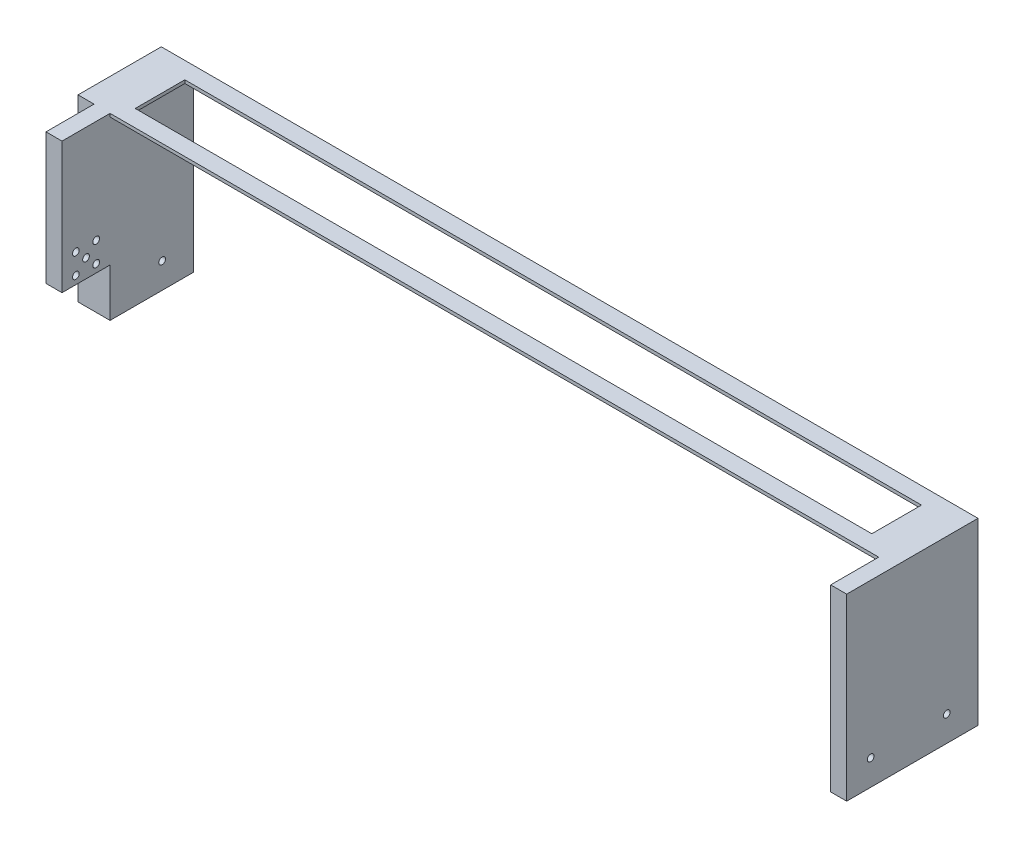
from build123d import *

# Parameters (mm, degrees)
BOSS_EXTRUDE1_DEPTH      = 82
BOSS_EXTRUDE1_DEPTH_BACK = 0.001
SKETCH2_W                = 480
SKETCH2_H                = 80
CUT_EXTRUDE2_DEPTH       = 82
SKETCH3_W                = 20
SKETCH3_H                = 52
SKETCH3_W_2              = 10
SKETCH3_H_2              = 82
BOSS_EXTRUDE3_DEPTH      = 30
SKETCH4_R                = 2.1
CUT_EXTRUDE3_DEPTH       = 618
SKETCH5_W                = 460.000000001
SKETCH5_H                = 31
CUT_EXTRUDE4_DEPTH       = 42
SKETCH6_R                = 2.1
CUT_EXTRUDE5_DEPTH       = 10


with BuildPart() as part:
    # Sketch1 → Boss-Extrude1 (new body, two sides)
    with BuildSketch(Plane(origin=(0, 0, 0), x_dir=(1, 0, 0), z_dir=(0, 1, 0))) as boss_extrude1_sk:
        Polygon((10, -82), (10, -52), (0, -52), (0, 0), (510, 0), (510, -82), (500, -82), (500, -52), (20, -52), (20, -82), align=None)
    extrude(amount=BOSS_EXTRUDE1_DEPTH)
    extrude(boss_extrude1_sk.sketch, amount=-BOSS_EXTRUDE1_DEPTH_BACK)

    # Sketch2 → Cut-Extrude2 (cut)
    with BuildSketch(Plane.XY):
        with Locations((260, 39.999)):
            Rectangle(SKETCH2_W, SKETCH2_H)
    extrude(amount=CUT_EXTRUDE2_DEPTH, mode=Mode.SUBTRACT)

    # Sketch3 → Boss-Extrude3 (add)
    with BuildSketch(Plane(origin=(0, 0, 0), x_dir=(1, 0, 0), z_dir=(0, 1, 0))):
        with Locations((10, -26)):
            Rectangle(SKETCH3_W, SKETCH3_H)
        with Locations((505, -41)):
            Rectangle(SKETCH3_W_2, SKETCH3_H_2)
    extrude(amount=-BOSS_EXTRUDE3_DEPTH)

    # Sketch4 → Cut-Extrude3 (cut)
    with BuildSketch(Plane(origin=(510, 0, 0), x_dir=(0, 0, -1), z_dir=(1, 0, 0))):
        with Locations((-67, -14.051)):
            Circle(SKETCH4_R)
        with Locations((-19.50000001, -14.05)):
            Circle(SKETCH4_R)
    extrude(amount=-CUT_EXTRUDE3_DEPTH, mode=Mode.SUBTRACT)

    # Sketch5 → Cut-Extrude4 (cut)
    with BuildSketch(Plane(origin=(0, 82, 0), x_dir=(1, 0, 0), z_dir=(0, 1, 0))):
        with Locations((255.200000001, -26)):
            Rectangle(SKETCH5_W, SKETCH5_H)
    extrude(amount=-CUT_EXTRUDE4_DEPTH, mode=Mode.SUBTRACT)

    # Sketch6 → Cut-Extrude5 (cut)
    with BuildSketch(Plane(origin=(20, 0, 0), x_dir=(0, 0, -1), z_dir=(1, 0, 0))):
        with Locations((-67, 11.349)):
            Circle(SKETCH6_R)
        with Locations((-60.65, 17.699)):
            Circle(SKETCH6_R)
        with Locations((-73.35, 17.699)):
            Circle(SKETCH6_R)
        with Locations((-73.35, 4.999)):
            Circle(SKETCH6_R)
        with Locations((-60.65, 4.999)):
            Circle(SKETCH6_R)
    extrude(amount=-CUT_EXTRUDE5_DEPTH, mode=Mode.SUBTRACT)


solid = part.part
